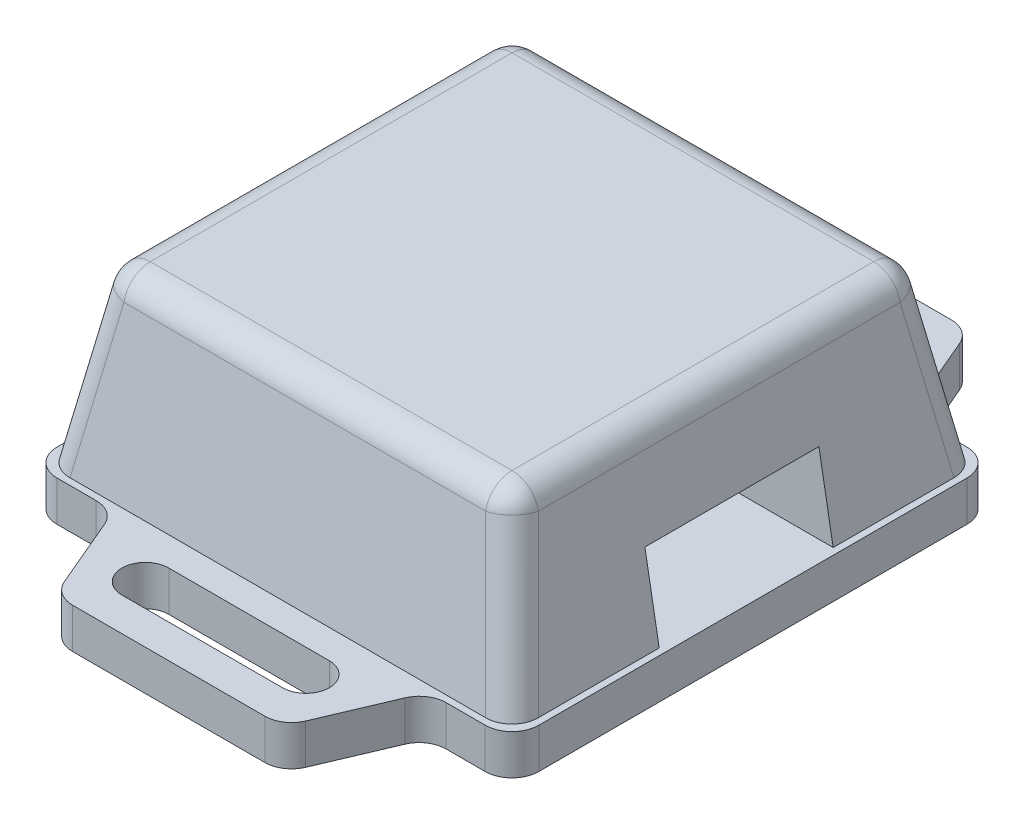
from build123d import *

# Parameters (mm, degrees)
SKETCH_1_W          = 36
SKETCH_1_H          = 51.3
EXTRUDE_1_DEPTH     = 3
CUT_EXTRUDE_1_DEPTH = 3
SKETCH_5_W          = 30.38
SKETCH_5_H          = 30.38
SKETCH_4_W          = 35
SKETCH_4_H          = 35
FILLET_1_R          = 2
CUT_EXTRUDE_3_DEPTH = 13
FILLET_2_R          = 2
SKETCH_8_R          = 2.75
CUT_EXTRUDE_4_DEPTH = 0.5
MM_2_D              = 2
MM_2_DEPTH          = 5
MM_2_TIP            = 0.600860619
CUT_EXTRUDE_START   = 10
SKETCH_16_W         = 13
SKETCH_16_H         = 6
CUT_EXTRUDE_5_DEPTH = 9.0000001


with BuildPart() as part:
    # 草图1 → 凸台-拉伸1 (new body)
    with BuildSketch(Plane(origin=(0, 0, 0), x_dir=(1, 0, 0), z_dir=(0, 1, 0))):
        Rectangle(SKETCH_1_W, SKETCH_1_H)
    extrude(amount=EXTRUDE_1_DEPTH)

    # 草图2 → 切除-拉伸1 (cut)
    with BuildSketch(Plane(origin=(0, 3, 0), x_dir=(1, 0, 0), z_dir=(0, 1, 0))):
        with BuildLine():
            Line((-6, 23.15), (6, 23.15))
            ThreePointArc((6, 23.15), (7.75, 21.4), (6, 19.65))
            Line((6, 19.65), (-6, 19.65))
            ThreePointArc((-6, 19.65), (-7.75, 21.4), (-6, 23.15))
        make_face()
        with BuildLine():
            Line((-6, -23.15), (6, -23.15))
            ThreePointArc((6, -23.15), (7.75, -21.4), (6, -19.65))
            Line((6, -19.65), (-6, -19.65))
            ThreePointArc((-6, -19.65), (-7.75, -21.4), (-6, -23.15))
        make_face()
    extrude(amount=-CUT_EXTRUDE_1_DEPTH, mode=Mode.SUBTRACT)

    # 草图5 → 放样1 section 0
    with BuildSketch(Plane(origin=(0, 16, 0), x_dir=(1, 0, 0), z_dir=(0, 1, 0))):
        Rectangle(SKETCH_5_W, SKETCH_5_H)
    # 草图4 → 放样1 section 1
    with BuildSketch(Plane(origin=(0, 3, 0), x_dir=(1, 0, 0), z_dir=(0, 1, 0))):
        Rectangle(SKETCH_4_W, SKETCH_4_H)
    loft()

    # 圆角1
    fillet_1_edges = [part.edges().sort_by_distance(p)[0] for p in [
        (0, 16, 15.19),
        (-15.19, 16, 0),
        (0, 16, -15.19),
        (15.19, 16, 0),
        (16.345, 9.5, -16.345),
        (16.345, 9.5, 16.345),
        (-16.345, 9.5, 16.345),
        (-16.345, 9.5, -16.345),
    ]]
    fillet(fillet_1_edges, radius=FILLET_1_R)

    # 草图6 → 切除-拉伸3 (cut)
    with BuildSketch(Plane(origin=(0, 3, 0), x_dir=(1, 0, 0), z_dir=(0, 1, 0))):
        Polygon((-8.5, 25.65), (-11.75, 18), (-18, 18), (-18, 25.65), align=None)
        Polygon((18, 25.65), (8.5, 25.65), (11.75, 18), (18, 18), align=None)
        Polygon((8.5, -25.65), (11.75, -18), (18, -18), (18, -25.65), align=None)
        Polygon((-18, -25.65), (-8.5, -25.65), (-11.75, -18), (-18, -18), align=None)
    extrude(amount=-CUT_EXTRUDE_3_DEPTH, mode=Mode.SUBTRACT)

    # 圆角2
    fillet_2_edges = [part.edges().sort_by_distance(p)[0] for p in [
        (-8.5, 1.5, -25.65),
        (-11.75, 1.5, -18),
        (-18, 1.5, -18),
        (18, 1.5, -18),
        (11.75, 1.5, -18),
        (8.5, 1.5, -25.65),
        (8.5, 1.5, 25.65),
        (11.75, 1.5, 18),
        (18, 1.5, 18),
        (-18, 1.5, 18),
        (-11.75, 1.5, 18),
        (-8.5, 1.5, 25.65),
    ]]
    fillet(fillet_2_edges, radius=FILLET_2_R)

    # 草图8 → 切除-拉伸4 (cut)
    with BuildSketch(Plane.XZ):
        with Locations((-11.75, 11.75)):
            Circle(SKETCH_8_R)
        with Locations((11.75, -11.75)):
            Circle(SKETCH_8_R)
    extrude(amount=-CUT_EXTRUDE_4_DEPTH, mode=Mode.SUBTRACT)

    # 大小mm 暗销孔2
    with Locations(Plane(origin=(0, 0, 0), x_dir=(-1, 0, 0), z_dir=(0, -1, 0))):
        with Locations((11.75, -11.75), (-11.75, 11.75)):
            Hole(MM_2_D / 2, depth=MM_2_DEPTH)
            with Locations((0, 0, -(MM_2_DEPTH + MM_2_TIP / 2))):  # 118° drill point
                Cone(0, MM_2_D / 2, MM_2_TIP, mode=Mode.SUBTRACT)

    # 草图16 → 切除-拉伸5 (cut, through all)
    with BuildSketch(Plane(origin=(0, 0, 0), x_dir=(0, 0, -1), z_dir=(1, 0, 0)).offset(CUT_EXTRUDE_START)):
        with Locations((0, 6)):
            Rectangle(SKETCH_16_W, SKETCH_16_H)
    extrude(amount=CUT_EXTRUDE_5_DEPTH, mode=Mode.SUBTRACT)


solid = part.part
